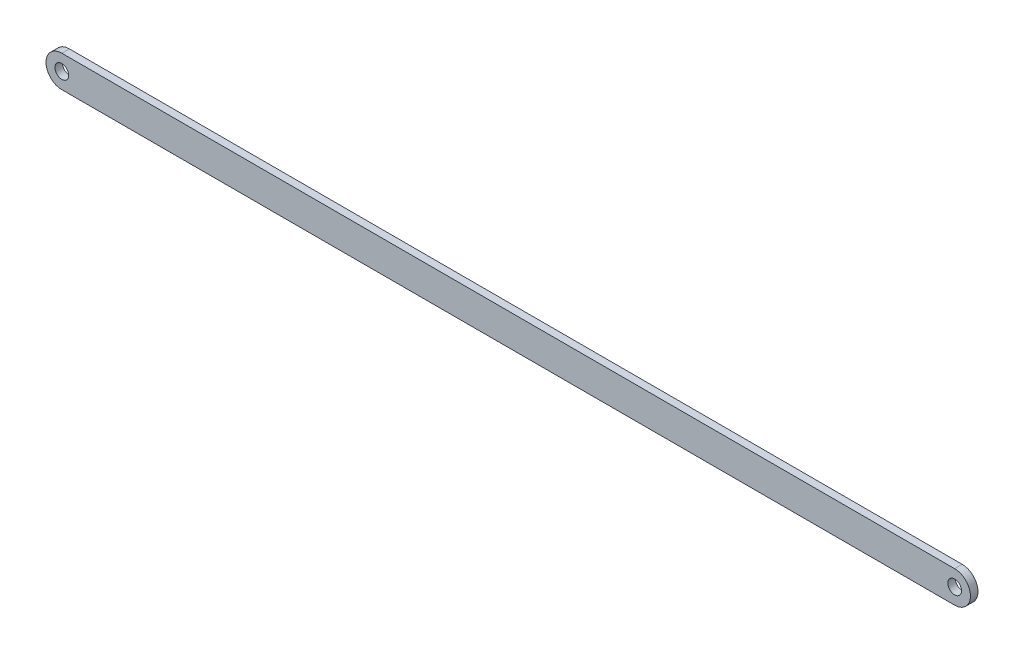
from build123d import *

# Parameters (mm, degrees)
SKETCH1_R           = 5
BOSS_EXTRUDE1_DEPTH = 2.75


with BuildPart() as part:
    # Sketch1 → Boss-Extrude1 (new body, symmetric)
    with BuildSketch(Plane.XY):
        with BuildLine():
            Line((-325, 11.5), (325, 11.5))
            ThreePointArc((325, 11.5), (336.5, 0), (325, -11.5))
            Line((325, -11.5), (-325, -11.5))
            ThreePointArc((-325, -11.5), (-336.5, 0), (-325, 11.5))
        make_face()
        with Locations((-325, 0)):
            Circle(SKETCH1_R, mode=Mode.SUBTRACT)
        with Locations((325, 0)):
            Circle(SKETCH1_R, mode=Mode.SUBTRACT)
    extrude(amount=BOSS_EXTRUDE1_DEPTH, both=True)


solid = part.part
